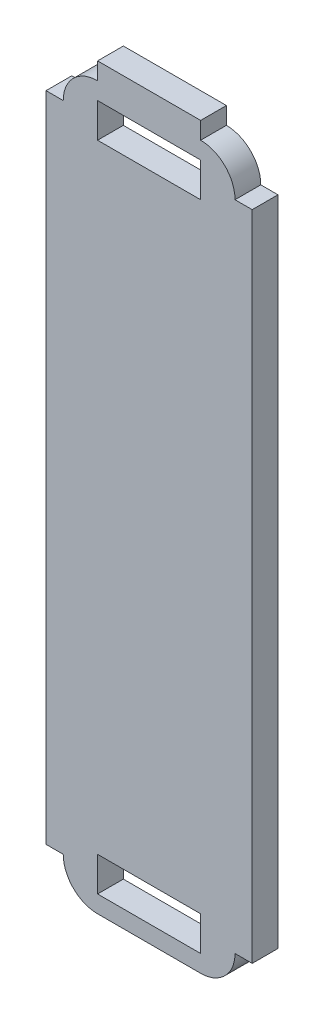
from build123d import *

# Parameters (mm, degrees)
SZKIC1_W                    = 10
SZKIC1_H                    = 42
DODANIE_WYCI_GNI_CIE1_DEPTH = 1.5
ZAOKR_GLENIE1_R             = 2
SZKIC2_W                    = 1.5
SZKIC2_H                    = 38
DODANIE_WYCI_GNI_CIE2_DEPTH = 1
SZKIC3_W                    = 1.5
SZKIC3_H                    = 38
DODANIE_WYCI_GNI_CIE3_DEPTH = 1
SZKIC4_W                    = 6
SZKIC4_H                    = 1.5
DODANIE_WYCI_GNI_CIE4_DEPTH = 1
SZKIC5_W                    = 6
SZKIC5_H                    = 2
WYTNIJ_WYCI_GNI_CIE2_DEPTH  = 2.5


with BuildPart() as part:
    # Szkic1 → Dodanie-wyciągnięcie1 (new body)
    with BuildSketch(Plane.XY):
        with Locations((5, 21)):
            Rectangle(SZKIC1_W, SZKIC1_H)
    extrude(amount=DODANIE_WYCI_GNI_CIE1_DEPTH)

    # Zaokrąglenie1
    zaokr_glenie1_edges = [part.edges().sort_by_distance(p)[0] for p in [
        (0, 42, 0.75),
        (10, 42, 0.75),
        (10, 0, 0.75),
        (0, 0, 0.75),
    ]]
    fillet(zaokr_glenie1_edges, radius=ZAOKR_GLENIE1_R)

    # Szkic2 → Dodanie-wyciągnięcie2 (add)
    with BuildSketch(Plane(origin=(10, 0, 0), x_dir=(0, 0, -1), z_dir=(1, 0, 0))):
        with Locations((-0.75, 21)):
            Rectangle(SZKIC2_W, SZKIC2_H)
    extrude(amount=DODANIE_WYCI_GNI_CIE2_DEPTH)

    # Szkic3 → Dodanie-wyciągnięcie3 (add)
    with BuildSketch(Plane.ZY):
        with Locations((0.75, 21)):
            Rectangle(SZKIC3_W, SZKIC3_H)
    extrude(amount=DODANIE_WYCI_GNI_CIE3_DEPTH)

    # Szkic4 → Dodanie-wyciągnięcie4 (add)
    with BuildSketch(Plane(origin=(0, 42, 0), x_dir=(1, 0, 0), z_dir=(0, 1, 0))):
        with Locations((5, -0.75)):
            Rectangle(SZKIC4_W, SZKIC4_H)
    extrude(amount=DODANIE_WYCI_GNI_CIE4_DEPTH)

    # Szkic5 → Wytnij-wyciągnięcie2 (cut, through all)
    with BuildSketch(Plane(origin=(0, 0, 0), x_dir=(-1, 0, 0), z_dir=(0, 0, -1))):
        with Locations((-5, 40)):
            Rectangle(SZKIC5_W, SZKIC5_H)
        with Locations((-5, 2)):
            Rectangle(SZKIC5_W, SZKIC5_H)
    extrude(amount=-WYTNIJ_WYCI_GNI_CIE2_DEPTH, mode=Mode.SUBTRACT)


solid = part.part
